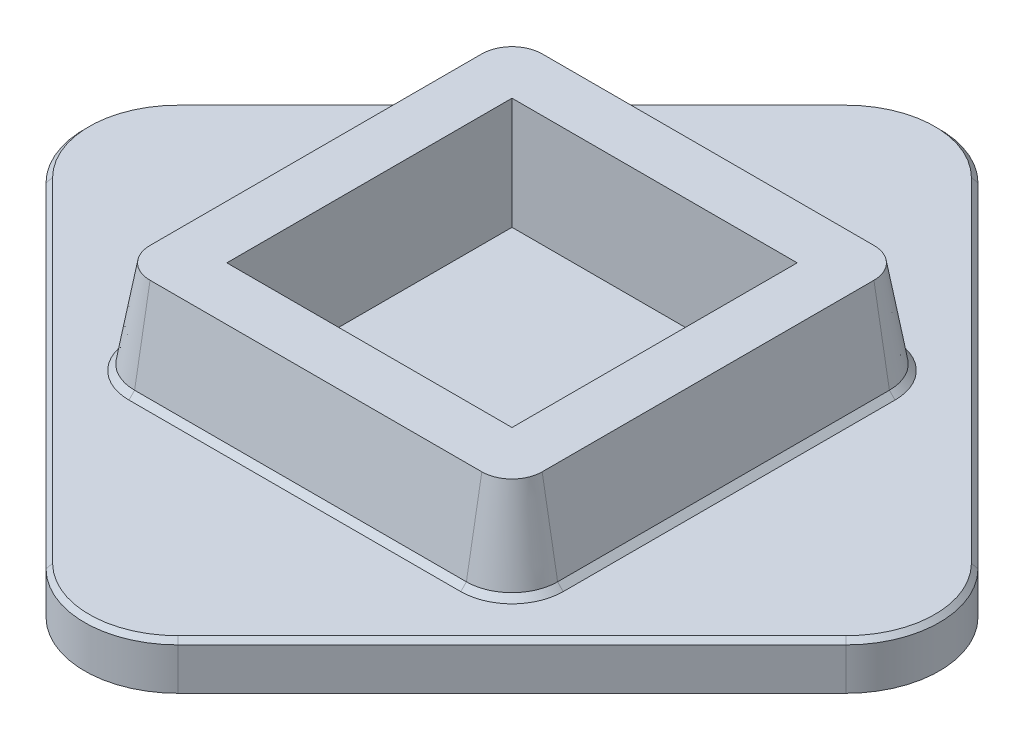
from build123d import *
from OCP.BRepFilletAPI import BRepFilletAPI_MakeChamfer

# Parameters (mm, degrees)
BOSS_EXTRUDE1_DEPTH = 5
BOSS_EXTRUDE2_START = 5
BOSS_EXTRUDE2_DEPTH = 10
BOSS_EXTRUDE2_TAPER = 10
CUT_EXTRUDE1_START  = 3
SKETCH1_5_W         = 30.6
SKETCH1_5_H         = 30.6
CUT_EXTRUDE1_DEPTH  = 12
CHAMFER1_SIZE       = 0.5
CHAMFER1_SIZE2      = 0.616401526


with BuildPart() as part:
    # Sketch1 → Boss-Extrude1 (new body)
    with BuildSketch(Plane(origin=(0, 0, 0), x_dir=(1, 0, 0), z_dir=(0, 1, 0))):
        with BuildLine():
            Line((7.071067812, -42.928932188), (42.928932188, -7.071067812))
            ThreePointArc((42.928932188, -7.071067812), (45.857864376, 0), (42.928932188, 7.071067812))
            Line((42.928932188, 7.071067812), (7.071067812, 42.928932188))
            ThreePointArc((7.071067812, 42.928932188), (0, 45.857864376), (-7.071067812, 42.928932188))
            Line((-7.071067812, 42.928932188), (-42.928932188, 7.071067812))
            ThreePointArc((-42.928932188, 7.071067812), (-45.857864376, 0), (-42.928932188, -7.071067812))
            Line((-42.928932188, -7.071067812), (-7.071067812, -42.928932188))
            ThreePointArc((-7.071067812, -42.928932188), (0, -45.857864376), (7.071067812, -42.928932188))
        make_face()
    extrude(amount=BOSS_EXTRUDE1_DEPTH)

    # Sketch1_4 → Boss-Extrude2 (add)
    with BuildSketch(Plane(origin=(0, 0, 0), x_dir=(1, 0, 0), z_dir=(0, 1, 0)).offset(BOSS_EXTRUDE2_START)):
        with BuildLine():
            ThreePointArc((17.8, -22.8), (21.335533906, -21.335533906), (22.8, -17.8))
            Line((22.8, -17.8), (22.8, 17.8))
            ThreePointArc((22.8, 17.8), (21.335533906, 21.335533906), (17.8, 22.8))
            Line((17.8, 22.8), (-17.8, 22.8))
            ThreePointArc((-17.8, 22.8), (-21.335533906, 21.335533906), (-22.8, 17.8))
            Line((-22.8, 17.8), (-22.8, -17.8))
            ThreePointArc((-22.8, -17.8), (-21.335533906, -21.335533906), (-17.8, -22.8))
            Line((-17.8, -22.8), (17.8, -22.8))
        make_face()
    extrude(amount=BOSS_EXTRUDE2_DEPTH, taper=BOSS_EXTRUDE2_TAPER)

    # Sketch1_5 → Cut-Extrude1 (cut)
    with BuildSketch(Plane(origin=(0, 0, 0), x_dir=(1, 0, 0), z_dir=(0, 1, 0)).offset(CUT_EXTRUDE1_START)):
        Rectangle(SKETCH1_5_W, SKETCH1_5_H)
    extrude(amount=CUT_EXTRUDE1_DEPTH, mode=Mode.SUBTRACT)

    # Chamfer1: one chamfer whose edges measure the first distance from different faces: ONE call of the kernel's chamfer builder (chamfer() names one face for all edges)
    chamfer1_edges_1 = [part.edges().sort_by_distance(p)[0] for p in [
        (0, 5, -45.857864376),
        (-25, 5, -25),
        (-45.857864376, 5, 0),
        (-25, 5, 25),
        (0, 5, 45.857864376),
        (25, 5, 25),
        (45.857864376, 5, 0),
        (25, 5, -25),
    ]]
    chamfer1_edges_2 = [part.edges().sort_by_distance(p)[0] for p in [
        (21.335533906, 5, -21.335533906),
        (-21.335533906, 5, -21.335533906),
        (-22.8, 5, 0),
        (-21.335533906, 5, 21.335533906),
        (0, 5, 22.8),
        (21.335533906, 5, 21.335533906),
        (22.8, 5, 0),
        (0, 5, -22.8),
    ]]
    chamfer1_side_2 = [part.faces().sort_by_distance(p)[0] for p in [
        (24.082842712, 5, 24.082842712),
    ]]
    chamfer1 = BRepFilletAPI_MakeChamfer(part.part.solid().wrapped)
    for e in chamfer1_edges_1:
        chamfer1.Add(CHAMFER1_SIZE, e.wrapped)
    for e in chamfer1_edges_2:
        chamfer1.Add(CHAMFER1_SIZE, CHAMFER1_SIZE2, e.wrapped, chamfer1_side_2[0].wrapped)  # the first distance lies on this face
    add(Compound.cast(chamfer1.Shape()), mode=Mode.REPLACE)


solid = part.part
